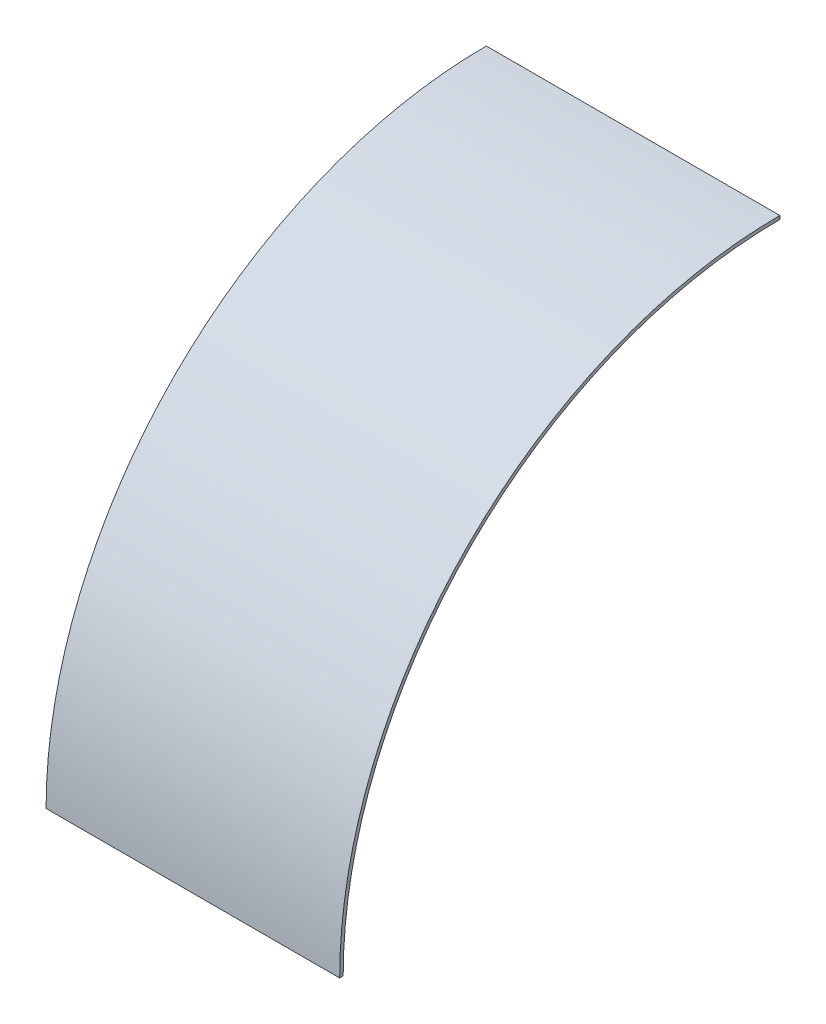
from build123d import *

# Parameters (mm, degrees)
EXTRUDE_THIN1_DEPTH = 133.35


with BuildPart() as part:
    # Sketch1 → Extrude-Thin1 (new body)
    with BuildSketch(Plane(origin=(0, 0, 0), x_dir=(0, 0, -1), z_dir=(1, 0, 0))):
        with BuildLine():
            ThreePointArc((0, 198.374), (-140.271600611, 140.271600611), (-198.374, 0))
            Line((-198.374, 0), (-199.9615, 0))
            ThreePointArc((-199.9615, 0), (-141.394132626, 141.394132626), (0, 199.9615))
            Line((0, 199.9615), (0, 198.374))
        make_face()
    extrude(amount=EXTRUDE_THIN1_DEPTH)


solid = part.part
